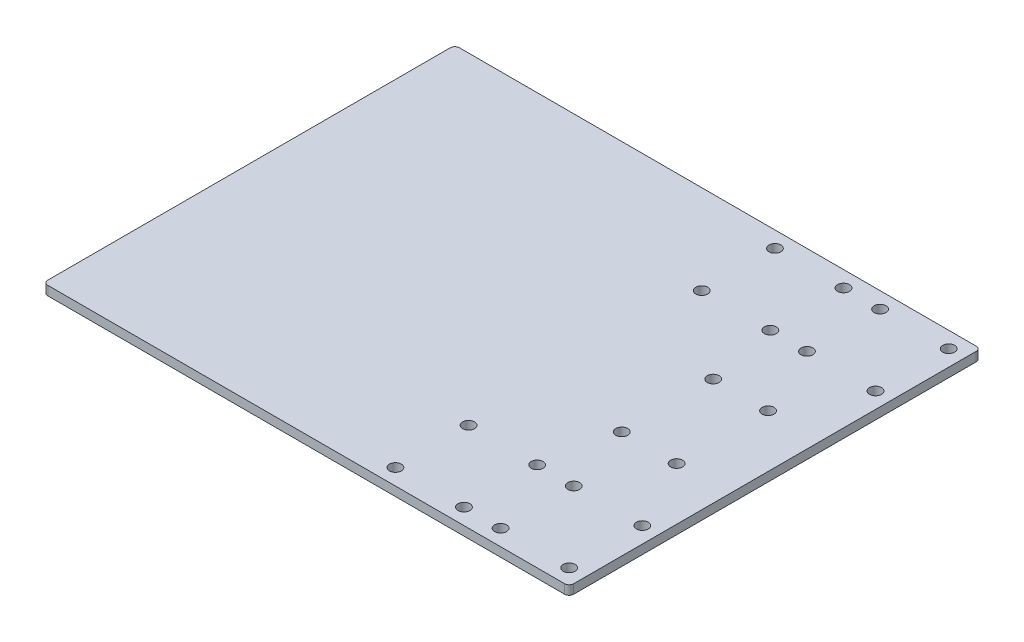
from build123d import *

# Parameters (mm, degrees)
SKETCH_1_W              = 230
SKETCH_1_H              = 180
EXTRUDE_1_DEPTH         = 4
HOLE_WIZARD_5_2_5_2_1_D = 5.2
FILLET_1_R              = 2


with BuildPart() as part:
    # Эскиз1 → Бобышка-Вытянуть1 (new body)
    with BuildSketch(Plane(origin=(0, 0, 0), x_dir=(1, 0, 0), z_dir=(0, 1, 0))):
        with Locations((115, 90)):
            Rectangle(SKETCH_1_W, SKETCH_1_H)
    extrude(amount=EXTRUDE_1_DEPTH)

    # Диаметр отверстия Ø5.2 (5.2)1 (through all)
    with Locations(Plane(origin=(0, 4, 0), x_dir=(1, 0, 0), z_dir=(0, 1, 0))):
        with Locations((183, 70), (183, 110), (207, 70), (207, 110), (223, 39), (223, 7), (193, 7), (193, 39), (147, 39), (177, 39), (147, 7), (177, 7), (193, 173), (223, 173), (223, 141), (193, 141), (177, 173), (147, 173), (177, 141), (147, 141)):
            Hole(HOLE_WIZARD_5_2_5_2_1_D / 2)

    # Скругление1
    fillet_1_edges = [part.edges().sort_by_distance(p)[0] for p in [
        (0, 2, -180),
        (230, 2, -180),
        (230, 2, 0),
        (0, 2, 0),
    ]]
    fillet(fillet_1_edges, radius=FILLET_1_R)


solid = part.part
